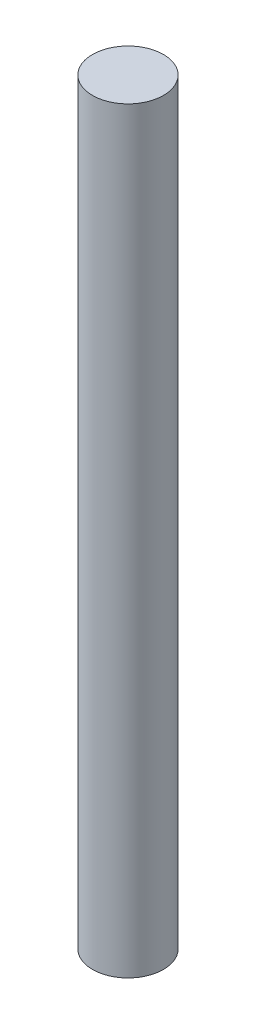
from build123d import *

# Parameters (mm, degrees)
SKETCH1_W        = 1.5
SKETCH1_H        = 32
EXTRUSION1_DEPTH = 9.3


with BuildPart() as part:
    # Sketch1 → Revolution1 (revolve)
    with BuildSketch(Plane(origin=(0, -7.683062836, 0), x_dir=(-1, 0, 0), z_dir=(0, 0, 1))):
        with Locations((0.75, 8.316937164)):
            Rectangle(SKETCH1_W, SKETCH1_H)
    revolve(axis=Axis((0, 0, 0), (0, -1, 0)))

    # Sketch2 → Extrusion1 (cut)
    with BuildSketch(Plane.XZ.offset(32)):
        with BuildLine():
            Line((-1, -1.118033989), (-1, 1.118033989))
            ThreePointArc((-1, 1.118033989), (-1.5, 0), (-1, -1.118033989))
        make_face()
    extrude(amount=-EXTRUSION1_DEPTH, mode=Mode.SUBTRACT)


solid = part.part
